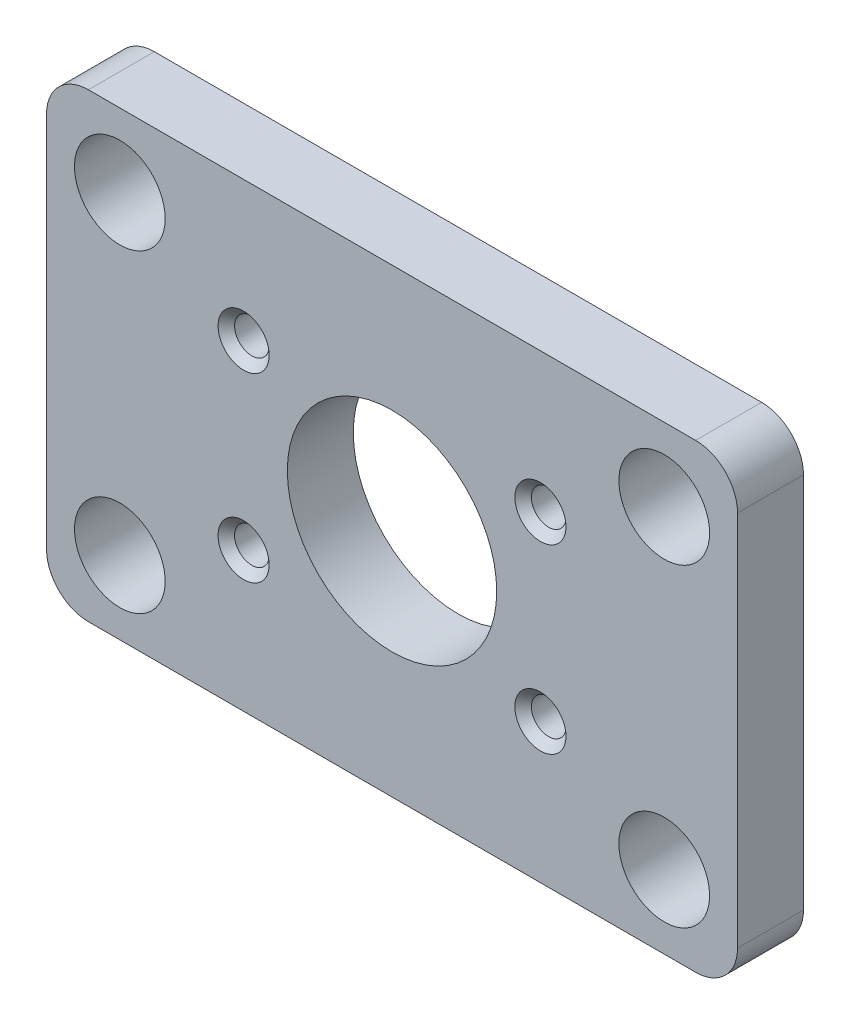
from build123d import *

# Parameters (mm, degrees)
SKETCH1_W           = 41.91
SKETCH1_H           = 27.94
SKETCH1_R           = 2.75
SKETCH1_R_2         = 1.05
SKETCH1_R_3         = 6.35
BOSS_EXTRUDE1_DEPTH = 4
FILLET1_R           = 2.54
CHAMFER1_SIZE       = 0.5


with BuildPart() as part:
    # Sketch1 → Boss-Extrude1 (new body)
    with BuildSketch(Plane.XY):
        Rectangle(SKETCH1_W, SKETCH1_H)
        with Locations((-16.51, 9.525)):
            Circle(SKETCH1_R, mode=Mode.SUBTRACT)
        with Locations((16.51, 9.525)):
            Circle(SKETCH1_R, mode=Mode.SUBTRACT)
        with Locations((16.51, -9.525)):
            Circle(SKETCH1_R, mode=Mode.SUBTRACT)
        with Locations((-16.51, -9.525)):
            Circle(SKETCH1_R, mode=Mode.SUBTRACT)
        with Locations((-9.00049, 5.50037)):
            Circle(SKETCH1_R_2, mode=Mode.SUBTRACT)
        with Locations((9.00049, -5.50037)):
            Circle(SKETCH1_R_2, mode=Mode.SUBTRACT)
        Circle(SKETCH1_R_3, mode=Mode.SUBTRACT)
        with Locations((-9.00049, -5.50037)):
            Circle(SKETCH1_R_2, mode=Mode.SUBTRACT)
        with Locations((9.00049, 5.50037)):
            Circle(SKETCH1_R_2, mode=Mode.SUBTRACT)
    extrude(amount=BOSS_EXTRUDE1_DEPTH)

    # Fillet1
    fillet1_edges = [part.edges().sort_by_distance(p)[0] for p in [
        (-20.955, 13.97, 2),
        (20.955, 13.97, 2),
        (20.955, -13.97, 2),
        (-20.955, -13.97, 2),
    ]]
    fillet(fillet1_edges, radius=FILLET1_R)

    # Chamfer1
    chamfer1_edges = [part.edges().sort_by_distance(p)[0] for p in [
        (7.95049, -5.50037, 4),
        (-10.05049, 5.50037, 4),
        (-10.05049, -5.50037, 4),
        (7.95049, 5.50037, 4),
    ]]
    chamfer(chamfer1_edges, length=CHAMFER1_SIZE)


solid = part.part
